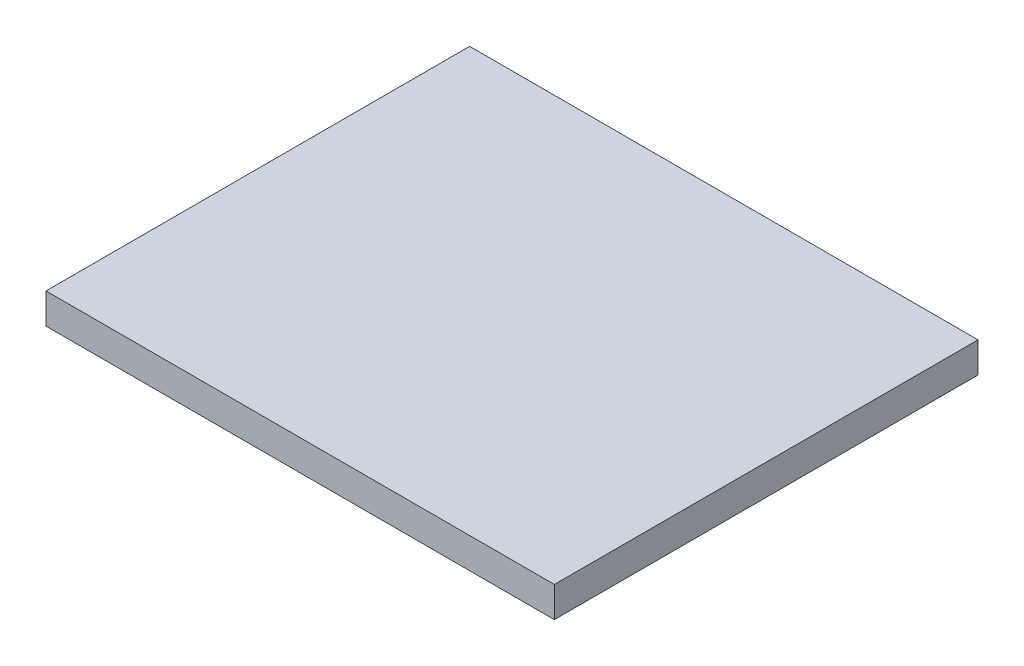
from build123d import *

# Parameters (mm, degrees)
ESQUISSE1_W        = 300
ESQUISSE1_H        = 250
BOSS_EXTRU_1_DEPTH = 18


with BuildPart() as part:
    # Esquisse1 → Boss.-Extru.1 (new body)
    with BuildSketch(Plane(origin=(0, 0, 0), x_dir=(1, 0, 0), z_dir=(0, 1, 0))):
        with Locations((81.950925179, -77.316866927)):
            Rectangle(ESQUISSE1_W, ESQUISSE1_H)
    extrude(amount=BOSS_EXTRU_1_DEPTH)


solid = part.part
